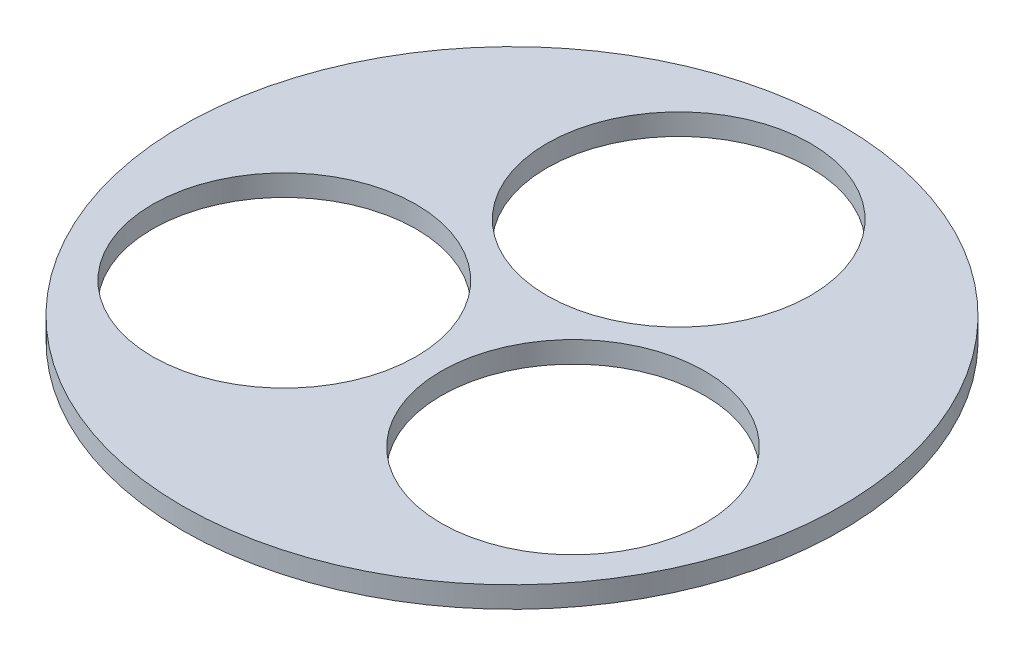
from build123d import *

# Parameters (mm, degrees)
SKETCH1_R           = 98.425
SKETCH1_R_2         = 39.37
BOSS_EXTRUDE1_DEPTH = 6.35


with BuildPart() as part:
    # Sketch1 → Boss-Extrude1 (new body)
    with BuildSketch(Plane(origin=(0, 0, 0), x_dir=(1, 0, 0), z_dir=(0, 1, 0))):
        Circle(SKETCH1_R)
        with Locations((0, 49.784)):
            Circle(SKETCH1_R_2, mode=Mode.SUBTRACT)
        with Locations((43.114208702, -24.892)):
            Circle(SKETCH1_R_2, mode=Mode.SUBTRACT)
        with Locations((-43.114208702, -24.892)):
            Circle(SKETCH1_R_2, mode=Mode.SUBTRACT)
    extrude(amount=BOSS_EXTRUDE1_DEPTH)


solid = part.part
